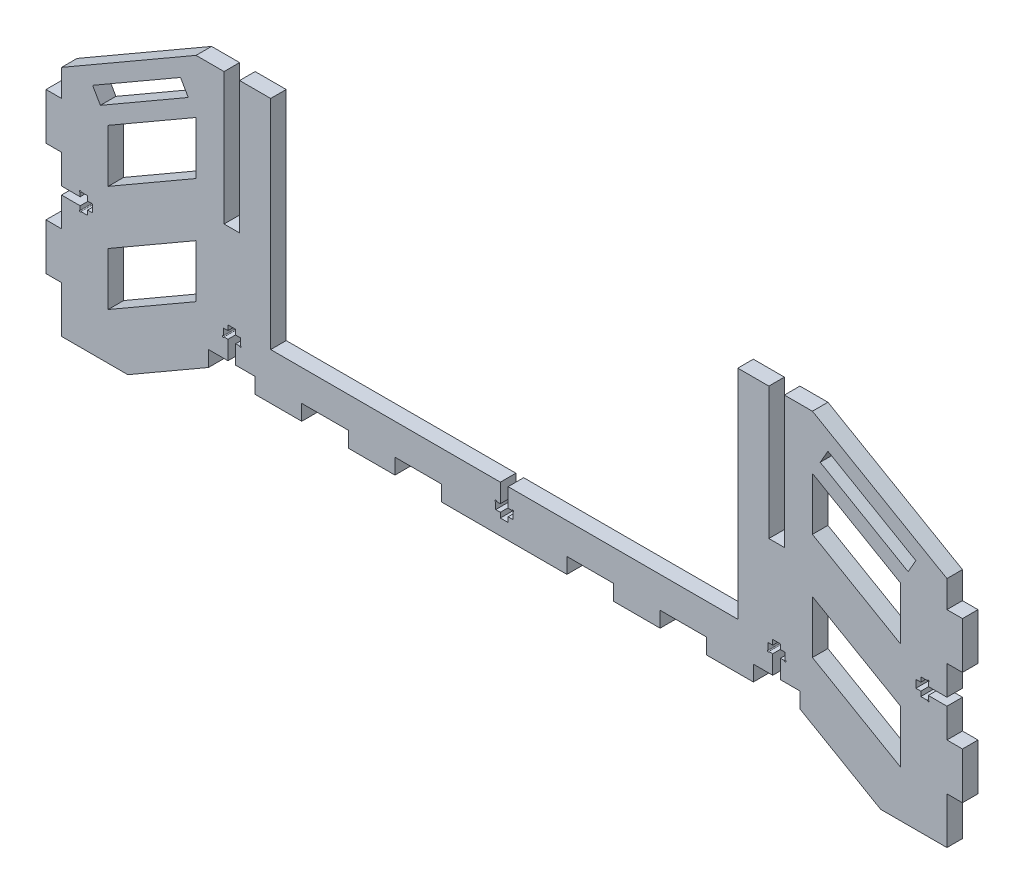
from build123d import *

# Parameters (mm, degrees)
ESTRUSIONE_ESTRUSIONE1_DEPTH = 5
TAGLIO_ESTRUSIONE2_DEPTH     = 6
SCHIZZO5_W                   = 15
SCHIZZO5_H                   = 5
SCHIZZO5_W_2                 = 5
SCHIZZO5_H_2                 = 42.5
SCHIZZO5_W_3                 = 150.358983848
SCHIZZO5_H_3                 = 70
TAGLIO_ESTRUSIONE3_DEPTH     = 6
TAGLIO_ESTRUSIONE4_DEPTH     = 6
SCHIZZO7_R                   = 0.25
TAGLIO_ESTRUSIONE5_DEPTH     = 10


with BuildPart() as part:
    # Schizzo1 → Estrusione-Estrusione1 (new body)
    with BuildSketch(Plane.XY):
        Polygon((-142.5, 75), (-142.5, 66.339745962), (-147.5, 66.339745962), (-147.5, 51.339745962), (-142.5, 51.339745962), (-142.5, 30), (-147.5, 30), (-147.5, 15), (-142.5, 15), (-142.5, 0), (142.5, 0), (142.5, 15), (147.5, 15), (147.5, 30), (142.5, 30), (142.5, 51.339745962), (147.5, 51.339745962), (147.5, 66.339745962), (142.5, 66.339745962), (142.5, 75), (99.198729811, 100), (-99.198729811, 100), align=None)
    extrude(amount=ESTRUSIONE_ESTRUSIONE1_DEPTH)

    # Schizzo2 → Taglio-Estrusione2 (cut, through all)
    with BuildSketch(Plane.XY):
        Polygon((-99.198729811, 82.679491924), (-127.5, 66.339745962), (-127.5, 49.330127019), (-99.198729811, 65.669872981), align=None)
        Polygon((99.198729811, 31.339745962), (99.198729811, 48.349364905), (127.5, 32.009618943), (127.5, 15), align=None)
        Polygon((-95.179491924, 15), (-121.160254038, 0), (121.160254038, 0), (95.179491924, 15), align=None)
        Polygon((-99.198729811, 31.339745962), (-127.5, 15), (-127.5, 32.009618943), (-99.198729811, 48.349364905), align=None)
        Polygon((99.198729811, 65.669872981), (99.198729811, 82.679491924), (127.5, 66.339745962), (127.5, 49.330127019), align=None)
        Polygon((-132.5, 75), (-104.198729811, 91.339745962), (-101.698729811, 87.009618943), (-130, 70.669872981), align=None)
        Polygon((132.5, 75), (130, 70.669872981), (101.698729811, 87.009618943), (104.198729811, 91.339745962), align=None)
    extrude(amount=TAGLIO_ESTRUSIONE2_DEPTH, mode=Mode.SUBTRACT)

    # Schizzo5 → Taglio-Estrusione3 (cut, through all)
    with BuildSketch(Plane.XY):
        with Locations((-87.679491924, 17.5)):
            Rectangle(SCHIZZO5_W, SCHIZZO5_H)
        with Locations((-57.679491924, 17.5)):
            Rectangle(SCHIZZO5_W, SCHIZZO5_H)
        with Locations((-27.679491924, 17.5)):
            Rectangle(SCHIZZO5_W, SCHIZZO5_H)
        with Locations((27.679491924, 17.5)):
            Rectangle(SCHIZZO5_W, SCHIZZO5_H)
        with Locations((57.679491924, 17.5)):
            Rectangle(SCHIZZO5_W, SCHIZZO5_H)
        with Locations((87.679491924, 17.5)):
            Rectangle(SCHIZZO5_W, SCHIZZO5_H)
        with Locations((87.679491924, 78.75)):
            Rectangle(SCHIZZO5_W_2, SCHIZZO5_H_2)
        with Locations((-87.679491924, 78.75)):
            Rectangle(SCHIZZO5_W_2, SCHIZZO5_H_2)
        with Locations((0, 65)):
            Rectangle(SCHIZZO5_W_3, SCHIZZO5_H_3)
    extrude(amount=TAGLIO_ESTRUSIONE3_DEPTH, mode=Mode.SUBTRACT)

    # Schizzo6 → Taglio-Estrusione4 (cut, through all)
    with BuildSketch(Plane.XY):
        Polygon((-142.5, 41.919872981), (-136.5, 41.919872981), (-136.5, 43.419872981), (-134.1, 43.419872981), (-134.1, 41.919872981), (-132.5, 41.919872981), (-132.5, 39.419872981), (-134.1, 39.419872981), (-134.1, 37.919872981), (-136.5, 37.919872981), (-136.5, 39.419872981), (-142.5, 39.419872981), align=None)
        Polygon((134.1, 43.419872981), (134.1, 41.919872981), (132.5, 41.919872981), (132.5, 39.419872981), (134.1, 39.419872981), (134.1, 37.919872981), (136.5, 37.919872981), (136.5, 39.419872981), (142.5, 39.419872981), (142.5, 41.919872981), (136.5, 41.919872981), (136.5, 43.419872981), align=None)
        Polygon((-88.929491924, 20), (-88.929491924, 26), (-90.429491924, 26), (-90.429491924, 28.4), (-88.929491924, 28.4), (-88.929491924, 30), (-86.429491924, 30), (-86.429491924, 28.4), (-84.929491924, 28.4), (-84.929491924, 26), (-86.429491924, 26), (-86.429491924, 20), align=None)
        Polygon((86.429491924, 20), (88.929491924, 20), (88.929491924, 26), (90.429491924, 26), (90.429491924, 28.4), (88.929491924, 28.4), (88.929491924, 30), (86.429491924, 30), (86.429491924, 28.4), (84.929491924, 28.4), (84.929491924, 26), (86.429491924, 26), align=None)
        Polygon((-1.25, 20), (-1.25, 21.6), (-2.75, 21.6), (-2.75, 24), (-1.25, 24), (-1.25, 30), (1.25, 30), (1.25, 24), (2.75, 24), (2.75, 21.6), (1.25, 21.6), (1.25, 20), align=None)
    extrude(amount=TAGLIO_ESTRUSIONE4_DEPTH, mode=Mode.SUBTRACT)

    # Schizzo7 → Taglio-Estrusione5 (cut)
    with BuildSketch(Plane.XY.offset(5)):
        with Locations((-136.5, 43.419872981)):
            Circle(SCHIZZO7_R)
        with Locations((-136.5, 37.919872981)):
            Circle(SCHIZZO7_R)
        with Locations((-90.429491924, 26)):
            Circle(SCHIZZO7_R)
        with Locations((-84.929491924, 26)):
            Circle(SCHIZZO7_R)
        with Locations((-2.75, 24)):
            Circle(SCHIZZO7_R)
        with Locations((2.75, 24)):
            Circle(SCHIZZO7_R)
        with Locations((84.929491924, 26)):
            Circle(SCHIZZO7_R)
        with Locations((90.429491924, 26)):
            Circle(SCHIZZO7_R)
        with Locations((136.5, 43.419872981)):
            Circle(SCHIZZO7_R)
        with Locations((136.5, 37.919872981)):
            Circle(SCHIZZO7_R)
    extrude(amount=-TAGLIO_ESTRUSIONE5_DEPTH, mode=Mode.SUBTRACT)


solid = part.part
